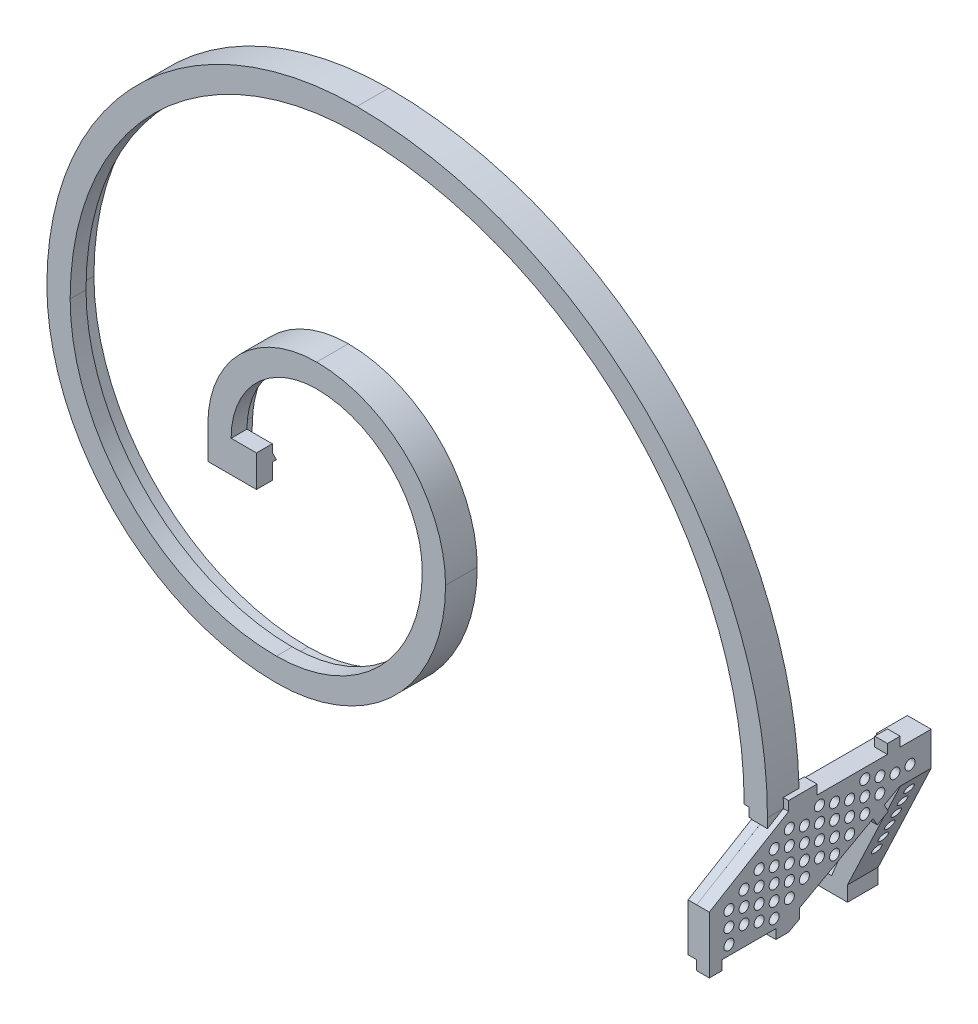
from build123d import *

# Parameters (mm, degrees)
EXTRUDE2_DEPTH     = 5
EXTRUDE3_DEPTH     = 5
EXTRUDE4_DEPTH     = 9.5
CUT_EXTRUDE1_DEPTH = 8
SKETCH7_W          = 5
SKETCH7_H          = 10
EXTRUDE5_DEPTH     = 8
SKETCH8_W          = 3.5
SKETCH8_H          = 10
EXTRUDE6_DEPTH     = 30
SKETCH9_W          = 3.5
SKETCH9_H          = 30
EXTRUDE7_DEPTH     = 20
SKETCH11_W         = 3.5
SKETCH11_H         = 30
EXTRUDE8_DEPTH     = 30
CUT_EXTRUDE2_DEPTH = 5
SKETCH12_W         = 3.5
SKETCH12_H         = 10.67873513
EXTRUDE9_DEPTH     = 10
EXTRUDE10_DEPTH    = 10
CUT_EXTRUDE3_DEPTH = 15
CUT_EXTRUDE4_DEPTH = 5
CUT_EXTRUDE5_DEPTH = 1
EXTRUDE11_DEPTH    = 0.8
EXTRUDE12_DEPTH    = 4
EXTRUDE13_DEPTH    = 9.7
SKETCH22_R         = 1.5875
EXTRUDE14_DEPTH    = 4
SKETCH23_R         = 1.5875
EXTRUDE15_DEPTH    = 2


with BuildPart() as part:
    # Sketch2 → Extrude2 (new body)
    with BuildSketch(Plane.XY):
        with BuildLine():
            Line((-28.4875, 0), (-28.4875, -10))
            Line((-28.4875, -10), (-31.9875, -10))
            Line((-31.9875, -10), (-31.9875, 0))
            ThreePointArc((-31.9875, 0), (-22.618578163, 22.618578163), (0, 31.9875))
            ThreePointArc((0, 31.9875), (27.108706224, 20.758706224), (38.3375, -6.35))
            ThreePointArc((38.3375, -6.35), (23.388962345, -42.438962345), (-12.7, -57.3875))
            ThreePointArc((-12.7, -57.3875), (-62.259346526, -36.859346526), (-82.7875, 12.7))
            ThreePointArc((-82.7875, 12.7), (-54.819858769, 80.219858769), (12.7, 108.1875))
            ThreePointArc((12.7, 108.1875), (102.670499071, 70.920499071), (139.9375, -19.05))
            Line((139.9375, -19.05), (136.4375, -19.05))
            ThreePointArc((136.4375, -19.05), (100.195625337, 68.445625337), (12.7, 104.6875))
            ThreePointArc((12.7, 104.6875), (-52.344985034, 77.744985034), (-79.2875, 12.7))
            ThreePointArc((-79.2875, 12.7), (-59.784472792, -34.384472792), (-12.7, -53.8875))
            ThreePointArc((-12.7, -53.8875), (20.914088611, -39.964088611), (34.8375, -6.35))
            ThreePointArc((34.8375, -6.35), (24.63383249, 18.28383249), (0, 28.4875))
            ThreePointArc((0, 28.4875), (-20.143704429, 20.143704429), (-28.4875, 0))
        make_face()
    extrude(amount=EXTRUDE2_DEPTH)

    # Sketch3 → Extrude3 (add)
    with BuildSketch(Plane.XY.offset(5)):
        with BuildLine():
            Line((-26.9875, 0), (-26.9875, -10))
            Line((-26.9875, -10), (-31.9875, -10))
            Line((-31.9875, -10), (-31.9875, 0))
            ThreePointArc((-31.9875, 0), (-22.618578163, 22.618578163), (0, 31.9875))
            ThreePointArc((0, 31.9875), (27.108706224, 20.758706224), (38.3375, -6.35))
            ThreePointArc((38.3375, -6.35), (23.388962345, -42.438962345), (-12.7, -57.3875))
            ThreePointArc((-12.7, -57.3875), (-62.259346526, -36.859346526), (-82.7875, 12.7))
            ThreePointArc((-82.7875, 12.7), (-54.819858769, 80.219858769), (12.7, 108.1875))
            ThreePointArc((12.7, 108.1875), (102.670499071, 70.920499071), (139.9375, -19.05))
            Line((139.9375, -19.05), (134.9375, -19.05))
            ThreePointArc((134.9375, -19.05), (99.134965165, 67.384965165), (12.7, 103.1875))
            ThreePointArc((12.7, 103.1875), (-51.284324863, 76.684324863), (-77.7875, 12.7))
            ThreePointArc((-77.7875, 12.7), (-58.72381262, -33.32381262), (-12.7, -52.3875))
            ThreePointArc((-12.7, -52.3875), (19.853428439, -38.903428439), (33.3375, -6.35))
            ThreePointArc((33.3375, -6.35), (23.573172318, 17.223172318), (0, 26.9875))
            ThreePointArc((0, 26.9875), (-19.083044257, 19.083044257), (-26.9875, 0))
        make_face()
    extrude(amount=EXTRUDE3_DEPTH)

    # Sketch4 → Extrude4 (add)
    with BuildSketch(Plane(origin=(-28.4875, 0, 0), x_dir=(0, 0, -1), z_dir=(1, 0, 0))):
        Polygon((-5, -2.4), (-1.2, -10), (-5, -10), align=None)
    extrude(amount=EXTRUDE4_DEPTH)

    # Sketch6 → Cut-Extrude1 (cut)
    with BuildSketch(Plane(origin=(-18.9875, 0, 0), x_dir=(0, 0, -1), z_dir=(1, 0, 0))):
        Polygon((-5, -5), (-3.7, -5), (-1.2, -10), (-5, -10), align=None)
    extrude(amount=-CUT_EXTRUDE1_DEPTH, mode=Mode.SUBTRACT)

    # Sketch7 → Extrude5 (add)
    with BuildSketch(Plane(origin=(-26.9875, 0, 0), x_dir=(0, 0, -1), z_dir=(1, 0, 0))):
        with Locations((-7.5, -5)):
            Rectangle(SKETCH7_W, SKETCH7_H)
    extrude(amount=EXTRUDE5_DEPTH)

    # Sketch8 → Extrude6 (add)
    with BuildSketch(Plane.XZ.offset(19.05)):
        with Locations((138.1875, 5)):
            Rectangle(SKETCH8_W, SKETCH8_H)
    extrude(amount=EXTRUDE6_DEPTH)

    # Sketch9 → Extrude7 (add)
    with BuildSketch(Plane.XY.offset(10)):
        with Locations((138.1875, -34.05)):
            Rectangle(SKETCH9_W, SKETCH9_H)
    extrude(amount=EXTRUDE7_DEPTH)

    # Sketch11 → Extrude8 (add)
    with BuildSketch(Plane(origin=(0, 0, 0), x_dir=(-1, 0, 0), z_dir=(0, 0, -1))):
        with Locations((-138.1875, -34.05)):
            Rectangle(SKETCH11_W, SKETCH11_H)
    extrude(amount=EXTRUDE8_DEPTH)

    # Sketch10 → Cut-Extrude2 (cut)
    with BuildSketch(Plane(origin=(139.9375, 0, 0), x_dir=(0, 0, -1), z_dir=(1, 0, 0))):
        Polygon((-5, -49.05), (30, -29.72873513), (30, -49.05), align=None)
        Polygon((-30, -34.05), (-30, -19.05), (-10, -19.05), (-10, -22.05), align=None)
    extrude(amount=-CUT_EXTRUDE2_DEPTH, mode=Mode.SUBTRACT)

    # Sketch12 → Extrude9 (add)
    with BuildSketch(Plane(origin=(0, 0, -30), x_dir=(-1, 0, 0), z_dir=(0, 0, -1))):
        with Locations((-138.1875, -24.389367565)):
            Rectangle(SKETCH12_W, SKETCH12_H)
    extrude(amount=EXTRUDE9_DEPTH)

    # Sketch14 → Extrude10 (add)
    with BuildSketch(Plane.XY.offset(10)):
        with BuildLine():
            Line((-34.3375, 0), (-34.3375, -10))
            Line((-34.3375, -10), (-31.9875, -10))
            Line((-31.9875, -10), (-31.9875, 0))
            ThreePointArc((-31.9875, 0), (-22.618578163, 22.618578163), (0, 31.9875))
            ThreePointArc((0, 31.9875), (27.108706224, 20.758706224), (38.3375, -6.35))
            ThreePointArc((38.3375, -6.35), (23.388962345, -42.438962345), (-12.7, -57.3875))
            ThreePointArc((-12.7, -57.3875), (-62.273683115, -36.845005789), (-82.787488266, 12.740555862))
            ThreePointArc((-82.787488266, 12.740555862), (-54.800329664, 80.224688864), (12.699982959, 108.172802388))
            ThreePointArc((12.699982959, 108.172802388), (102.670493046, 70.905807484), (139.9375, -19.064697612))
            Line((139.9375, -19.064697612), (139.9375, -34.05))
            Line((139.9375, -34.05), (142.2875, -34.05))
            Line((142.2875, -34.05), (142.2875, -19.064697612))
            ThreePointArc((142.2875, -19.064697612), (104.332193871, 72.567508531), (12.699982644, 110.522802388))
            ThreePointArc((12.699982644, 110.522802388), (-56.461549873, 81.886870388), (-85.137487873, 12.741915681))
            ThreePointArc((-85.137487873, 12.741915681), (-63.93586475, -38.506225887), (-12.7, -59.7375))
            ThreePointArc((-12.7, -59.7375), (25.050663281, -44.100663281), (40.6875, -6.35))
            ThreePointArc((40.6875, -6.35), (28.77040716, 22.42040716), (0, 34.3375))
            ThreePointArc((0, 34.3375), (-24.280279099, 24.280279099), (-34.3375, 0))
        make_face()
    extrude(amount=-EXTRUDE10_DEPTH)

    # Sketch15 → Cut-Extrude3 (cut)
    with BuildSketch(Plane.ZY.offset(34.3375)):
        Polygon((0, 14), (0, -10), (1.2, -10), align=None)
    extrude(amount=-CUT_EXTRUDE3_DEPTH, mode=Mode.SUBTRACT)

    # Sketch16 → Cut-Extrude4 (cut)
    with BuildSketch(Plane(origin=(0, 0, 0), x_dir=(-1, 0, 0), z_dir=(0, 0, -1))):
        with BuildLine():
            Line((28.4875, 0), (29.4875, 0))
            ThreePointArc((29.4875, 0), (20.85081121, 20.85081121), (0, 29.4875))
            ThreePointArc((0, 29.4875), (-25.340939271, 18.990939271), (-35.8375, -6.35))
            ThreePointArc((-35.8375, -6.35), (-21.621195392, -40.671195392), (12.7, -54.8875))
            ThreePointArc((12.7, -54.8875), (60.491579573, -35.091579573), (80.2875, 12.7))
            ThreePointArc((80.2875, 12.7), (53.052091816, 78.452091816), (-12.7, 105.6875))
            ThreePointArc((-12.7, 105.6875), (-100.902732118, 69.152732118), (-137.4375, -19.05))
            Line((-137.4375, -19.05), (-136.4375, -34.05))
            Line((-136.4375, -34.05), (-136.4375, -19.05))
            ThreePointArc((-136.4375, -19.05), (-100.195625337, 68.445625337), (-12.7, 104.6875))
            ThreePointArc((-12.7, 104.6875), (52.344985034, 77.744985034), (79.2875, 12.7))
            ThreePointArc((79.2875, 12.7), (59.784472792, -34.384472792), (12.7, -53.8875))
            ThreePointArc((12.7, -53.8875), (-20.914088611, -39.964088611), (-34.8375, -6.35))
            ThreePointArc((-34.8375, -6.35), (-24.63383249, 18.28383249), (0, 28.4875))
            ThreePointArc((0, 28.4875), (20.143704429, 20.143704429), (28.4875, 0))
        make_face()
    extrude(amount=-CUT_EXTRUDE4_DEPTH, mode=Mode.SUBTRACT)

    # Sketch17 → Cut-Extrude5 (cut)
    with BuildSketch(Plane(origin=(-28.4875, 0, 0), x_dir=(0, 0, -1), z_dir=(1, 0, 0))):
        Polygon((-5, 0), (-5, -2.4), (-1.2, -10), (0, -10), (0, 0), align=None)
    extrude(amount=-CUT_EXTRUDE5_DEPTH, mode=Mode.SUBTRACT)

    # Sketch19 → Extrude11 (cut)
    with BuildSketch(Plane.ZY.offset(-136.4375)):
        Polygon((-30.2, -29.72873513), (-30, -29.72873513), (5, -49.05), (30, -49.05), (30, -33.816761924), (5.388730126, -19.05), (-30.2, -19.05), align=None)
    extrude(amount=-EXTRUDE11_DEPTH, mode=Mode.SUBTRACT)

    # Sketch20 → Extrude12 (add)
    with BuildSketch(Plane(origin=(139.9375, 0, 0), x_dir=(0, 0, -1), z_dir=(1, 0, 0))):
        Polygon((-30, -49.05), (-30, -34.05), (-5, -19.064697612), (-5, -16.05), (4, -16.05), (4, -19.05), (26.2, -19.05), (26.2, -16.05), (30.2, -16.05), (30.2, -19.05), (40, -19.05), (40, -29.72873513), (30, -29.72873513), (25.182396212, -32.388226525), (26.495533323, -34.766942369), (22.991066647, -36.695338934), (21.680550927, -34.321371676), (-1.475480862, -47.104338063), (-1.475480862, -50.158501958), (-5, -52.05), (-9, -52.05), (-9, -49.05), (-26, -49.05), (-26, -52.05), (-30, -52.05), align=None)
    extrude(amount=EXTRUDE12_DEPTH)

    # Sketch21 → Extrude13 (add)
    with BuildSketch(Plane(origin=(0, 0, -40), x_dir=(-1, 0, 0), z_dir=(0, 0, -1))):
        Polygon((-136.4375, -19.05), (-136.4375, -29.72873513), (-122.24, -65.09), (-115.7125, -65.0875), (-115.7125, -69.85), (-127.24, -69.85), (-127.24, -65.0875), (-143.9375, -29.72873513), (-143.9375, -19.05), align=None)
    extrude(amount=-EXTRUDE13_DEPTH)

    # Sketch22 → Extrude14 (cut)
    with BuildSketch(Plane(origin=(143.9375, 0, 0), x_dir=(0, 0, -1), z_dir=(1, 0, 0))):
        with Locations((-23.8125, -36.5125)):
            Circle(SKETCH22_R)
        with Locations((-19.05, -33.3375)):
            Circle(SKETCH22_R)
        with Locations((-14.2875, -30.1625)):
            Circle(SKETCH22_R)
        with Locations((-9.525, -26.9875)):
            Circle(SKETCH22_R)
        with Locations((-4.7625, -23.8125)):
            Circle(SKETCH22_R)
        with Locations((-23.8125, -41.275)):
            Circle(SKETCH22_R)
        with Locations((-19.05, -38.1)):
            Circle(SKETCH22_R)
        with Locations((-14.2875, -34.925)):
            Circle(SKETCH22_R)
        with Locations((-9.525, -31.75)):
            Circle(SKETCH22_R)
        with Locations((-4.7625, -28.575)):
            Circle(SKETCH22_R)
        with Locations((0, -25.4)):
            Circle(SKETCH22_R)
        with Locations((4.7625, -26.9875)):
            Circle(SKETCH22_R)
        with Locations((-23.8125, -46.0375)):
            Circle(SKETCH22_R)
        with Locations((-19.05, -42.8625)):
            Circle(SKETCH22_R)
        with Locations((-14.2875, -39.6875)):
            Circle(SKETCH22_R)
        with Locations((-9.525, -36.5125)):
            Circle(SKETCH22_R)
        with Locations((-4.7625, -33.3375)):
            Circle(SKETCH22_R)
        with Locations((0, -30.1625)):
            Circle(SKETCH22_R)
        with Locations((-14.2875, -44.45)):
            Circle(SKETCH22_R)
        with Locations((-9.525, -41.275)):
            Circle(SKETCH22_R)
        with Locations((-4.7625, -38.1)):
            Circle(SKETCH22_R)
        with Locations((0, -34.925)):
            Circle(SKETCH22_R)
        with Locations((4.7625, -31.75)):
            Circle(SKETCH22_R)
        with Locations((-9.525, -46.0375)):
            Circle(SKETCH22_R)
        with Locations((-4.7625, -42.8625)):
            Circle(SKETCH22_R)
        with Locations((0, -39.6875)):
            Circle(SKETCH22_R)
        with Locations((4.7625, -36.5125)):
            Circle(SKETCH22_R)
        with Locations((9.525, -33.3375)):
            Circle(SKETCH22_R)
        with Locations((9.525, -28.575)):
            Circle(SKETCH22_R)
        with Locations((9.525, -23.8125)):
            Circle(SKETCH22_R)
        with Locations((4.7625, -22.225)):
            Circle(SKETCH22_R)
        with Locations((14.2875, -30.1625)):
            Circle(SKETCH22_R)
        with Locations((14.2875, -25.4)):
            Circle(SKETCH22_R)
        with Locations((19.05, -26.9875)):
            Circle(SKETCH22_R)
        with Locations((19.05, -22.225)):
            Circle(SKETCH22_R)
        with Locations((9.525, -38.1)):
            Circle(SKETCH22_R)
        with Locations((14.2875, -34.925)):
            Circle(SKETCH22_R)
        with Locations((19.05, -31.75)):
            Circle(SKETCH22_R)
        with Locations((23.8125, -28.575)):
            Circle(SKETCH22_R)
        with Locations((23.8125, -23.8125)):
            Circle(SKETCH22_R)
        with Locations((28.575, -25.4)):
            Circle(SKETCH22_R)
        with Locations((33.3375, -25.4)):
            Circle(SKETCH22_R)
    extrude(amount=-EXTRUDE14_DEPTH, mode=Mode.SUBTRACT)

    # Sketch23 → Extrude15 (cut)
    with BuildSketch(Plane(origin=(129.170948149, -60.99850814, 0), x_dir=(0, 0, -1), z_dir=(0.90424563, -0.427012693, 0))):
        with Locations((34.925, 30.1625)):
            Circle(SKETCH23_R)
        with Locations((34.925, 25.4)):
            Circle(SKETCH23_R)
        with Locations((34.925, 20.6375)):
            Circle(SKETCH23_R)
        with Locations((34.925, 15.875)):
            Circle(SKETCH23_R)
        with Locations((34.925, 11.1125)):
            Circle(SKETCH23_R)
        with Locations((34.925, 6.35)):
            Circle(SKETCH23_R)
    extrude(amount=-EXTRUDE15_DEPTH, mode=Mode.SUBTRACT)


solid = part.part
